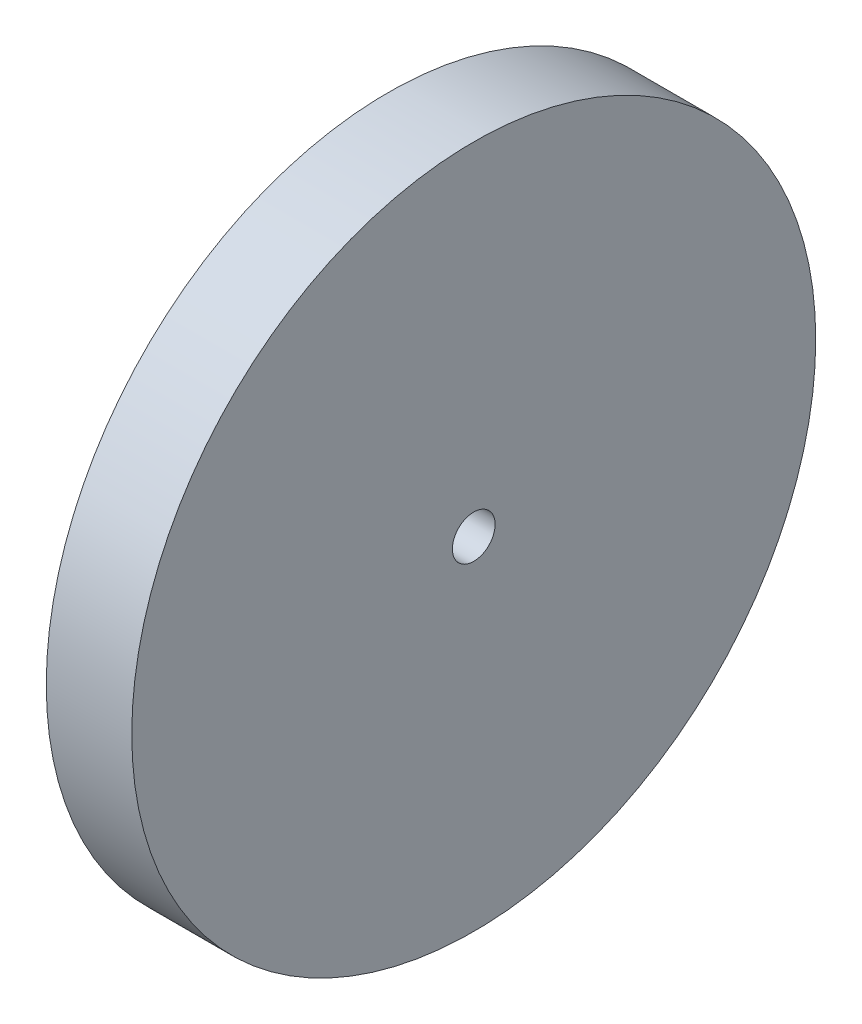
from build123d import *

# Parameters (mm, degrees)
SKETCH5_R          = 2.38125
CUT_EXTRUDE2_DEPTH = 55.74135876


with BuildPart() as part:
    # Sketch3 → Revolve1 (revolve)
    with BuildSketch(Plane(origin=(0, 0, 0), x_dir=(1, 0, 0), z_dir=(0, 1, 0))):
        Polygon((0, 0), (0, 38.1), (-9.525, 38.1), (-9.525, 28.575), (-3.314155064, 28.575), (-3.314155064, 15.875), (-9.664148049, 9.525007015), (-9.664148049, 7.015e-06), align=None)
    revolve(axis=Axis((-9.664148049, 0, -7.015e-06), (0.9999999999997365, 0, 7.259051948720745e-07)))

    # Sketch5 → Cut-Extrude2 (cut, through all)
    with BuildSketch(Plane(origin=(-9.664151506, 0, -7.015e-06), x_dir=(-7.25905194872075e-07, 0, 0.9999999999997367), z_dir=(-0.9999999999997367, 0, -7.25905194872075e-07))):
        Circle(SKETCH5_R)
    extrude(amount=-CUT_EXTRUDE2_DEPTH, mode=Mode.SUBTRACT)


solid = part.part
